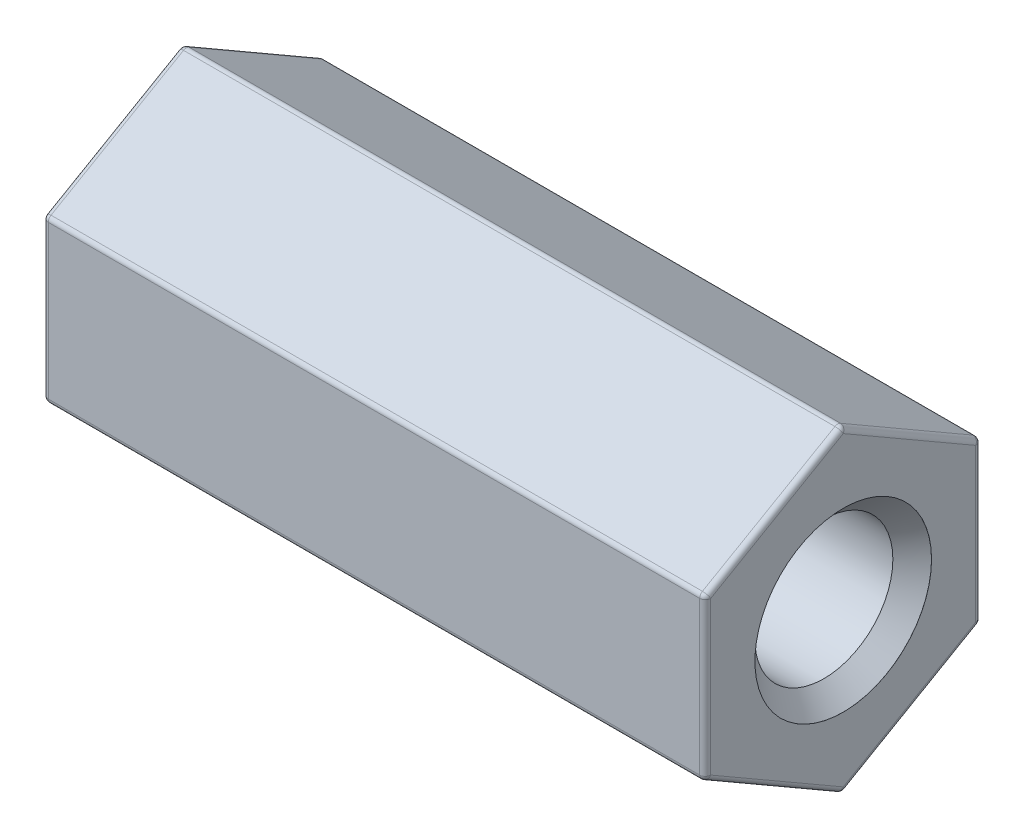
from build123d import *

# Parameters (mm, degrees)
BOSS_EXTRUDE1_DEPTH = 12
FILLET1_R           = 0.1


with BuildPart() as part:
    # Sketch1 → Boss-Extrude1 (new body)
    with BuildSketch(Plane(origin=(12, 0, 0), x_dir=(0, 0, -1), z_dir=(1, 0, 0))):
        Polygon((-2.5, 1.443375673), (-2.5, -1.443375673), (0, -2.886751346), (2.5, -1.443375673), (2.5, 1.443375673), (0, 2.886751346), align=None)
    extrude(amount=-BOSS_EXTRUDE1_DEPTH)

    # Sketch2 → Cut-Revolve1 (revolve, cut)
    with BuildSketch(Plane.XY):
        Polygon((0, 1.6), (0, 0), (12, 0), (12, 1.6), (11.649, 1.25), (0.351, 1.25), (0.001, 1.6), align=None)
    revolve(axis=Axis((0, 0, 0), (1, 0, 0)), mode=Mode.SUBTRACT)

    # Fillet1
    fillet1_edges = [part.edges().sort_by_distance(p)[0] for p in [
        (0, -2.165063509, 1.25),
        (6, 2.886751346, 0),
        (6, 1.443375673, -2.5),
        (6, -1.443375673, -2.5),
        (6, -2.886751346, 0),
        (6, -1.443375673, 2.5),
        (6, 1.443375673, 2.5),
        (0, -2.165063509, -1.25),
        (0, 0, -2.5),
        (0, 2.165063509, -1.25),
        (0, 2.165063509, 1.25),
        (12, 2.165063509, -1.25),
        (12, 0, -2.5),
        (12, -2.165063509, -1.25),
        (0, 0, 2.5),
        (12, -2.165063509, 1.25),
        (12, 0, 2.5),
        (12, 2.165063509, 1.25),
    ]]
    fillet(fillet1_edges, radius=FILLET1_R)


solid = part.part
